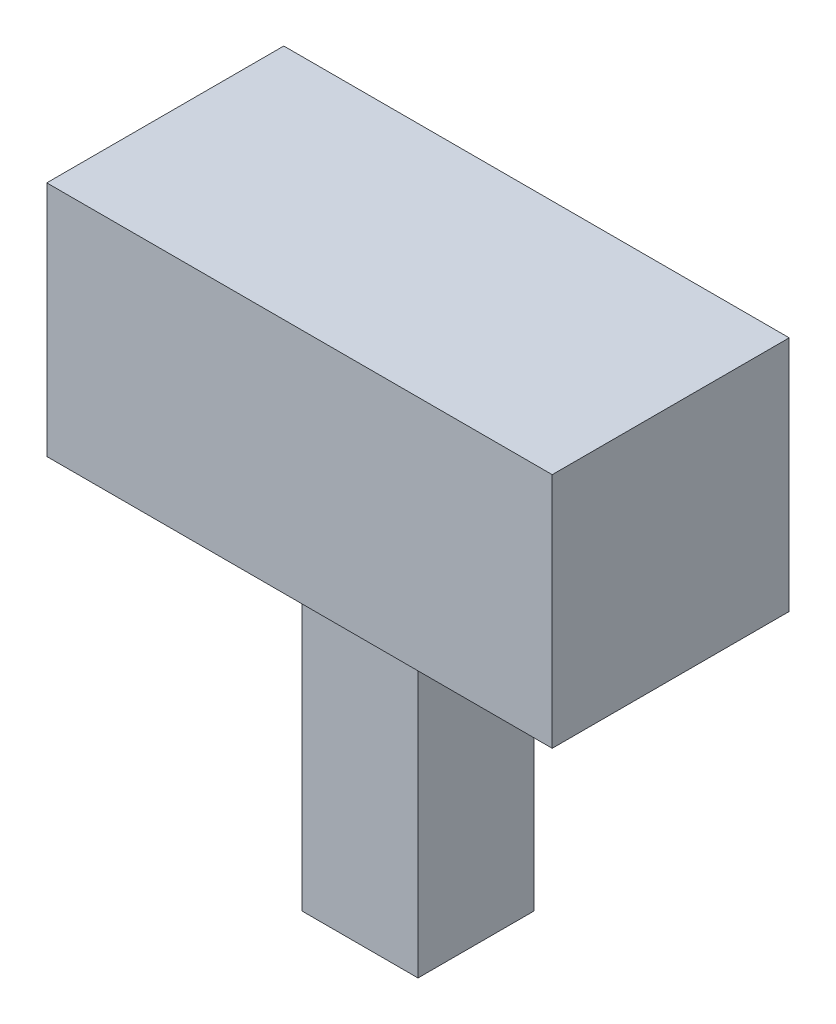
from build123d import *

# Parameters (mm, degrees)
SKETCH_1_W           = 9.8
SKETCH_1_H           = 9.8
EXTRUDE_1_DEPTH      = 9.8
SKETCH_2_W           = 4.8
SKETCH_2_H           = 4.8
EXTRUDE_2_DEPTH      = 13.5
SKETCH_4_W           = 9.8
SKETCH_4_H           = 9.8
EXTRUDE_4_DEPTH      = 5.55
SKETCH_6_W           = 9.8
SKETCH_6_H           = 9.8
EXTRUDE_5_DEPTH      = 5.55
EXTRUDE_5_DEPTH_BACK = 15.35
CUT_EXTRUDE_1_DEPTH  = 1
CUT_EXTRUDE_2_DEPTH  = 1


with BuildPart() as part:
    # 草图1 → 凸台-拉伸1 (new body)
    with BuildSketch(Plane.XY):
        with Locations((0.756375839, 0.263087248)):
            Rectangle(SKETCH_1_W, SKETCH_1_H)
    extrude(amount=EXTRUDE_1_DEPTH)

    # 草图2 → 凸台-拉伸2 (add)
    with BuildSketch(Plane.XZ.offset(4.636912752)):
        with Locations((0.756375839, 4.9)):
            Rectangle(SKETCH_2_W, SKETCH_2_H)
    extrude(amount=EXTRUDE_2_DEPTH)

    # 草图4 → 凸台-拉伸4 (add)
    with BuildSketch(Plane(origin=(5.656375839, 0, 0), x_dir=(0, 0, -1), z_dir=(1, 0, 0))):
        with Locations((-4.9, 0.263087248)):
            Rectangle(SKETCH_4_W, SKETCH_4_H)
    extrude(amount=EXTRUDE_4_DEPTH)

    # 草图6 → 凸台-拉伸5 (add, two sides)
    with BuildSketch(Plane.ZY.offset(4.143624161)) as extrude_5_sk:
        with Locations((4.9, 0.263087248)):
            Rectangle(SKETCH_6_W, SKETCH_6_H)
    extrude(amount=EXTRUDE_5_DEPTH)
    extrude(extrude_5_sk.sketch, amount=-EXTRUDE_5_DEPTH_BACK)

    # 草图7 → 切除-拉伸1 (cut)
    with BuildSketch(Plane(origin=(0, 0, 0), x_dir=(-1, 0, 0), z_dir=(0, 0, -1))):
        with BuildLine():
            Line((-1.929152879, 2.490221957), (-1.858302676, 2.490221957))
            add(Edge.make_bspline(
                [(-1.858302676, 2.490221957), (-1.856417734, 2.458896013), (-1.852718838, 2.397423866), (-1.845317525, 2.304589435), (-1.829200327, 2.209033175), (-1.807695249, 2.107132803), (-1.77108464, 2.001211747), (-1.724850314, 1.91644303), (-1.679762546, 1.85333673), (-1.642647564, 1.810720844), (-1.602372462, 1.773843029), (-1.560474354, 1.741280468), (-1.51488514, 1.716571146), (-1.466783788, 1.699901061), (-1.416690998, 1.690442876), (-1.365401815, 1.691476688), (-1.315799066, 1.696795833), (-1.269966968, 1.708456441), (-1.22823319, 1.722934541), (-1.190186404, 1.743766408), (-1.154241642, 1.773128147), (-1.119141922, 1.812535547), (-1.081677181, 1.861174561), (-1.043853344, 1.920197497), (-1.006982515, 1.988781029), (-0.973062721, 2.066952505), (-0.944757937, 2.154640595), (-0.918704793, 2.250181479), (-0.896861647, 2.353130154), (-0.877239021, 2.461229037), (-0.862549121, 2.574787435), (-0.855230874, 2.652035503), (-0.85148401, 2.69158569)],
                knots=[0, 0, 0, 0, 9.4159e-05, 0.000184772, 0.000279182, 0.000384666, 0.000496941, 0.000614078, 0.000672859, 0.000729406, 0.000783238, 0.000836487, 0.000888211, 0.000937978, 0.000988741, 0.001040201, 0.001091265, 0.001138113, 0.00118176, 0.001223484, 0.001267511, 0.001320288, 0.001381448, 0.001451576, 0.001530323, 0.001614835, 0.001706813, 0.001806498, 0.001911821, 0.00202242, 0.002136018, 0.002255198, 0.002255198, 0.002255198, 0.002255198], degree=3))
            Line((-0.85148401, 2.69158569), (-0.841788719, 2.988410748))
            Line((-0.841788719, 2.988410748), (-0.836568178, 3.18455394))
            add(Edge.make_bspline(
                [(-0.836568178, 3.18455394), (-0.843589049, 3.164594334), (-0.856830328, 3.126950758), (-0.878435789, 3.074712531), (-0.896514508, 3.028640339), (-0.919208562, 2.976418811), (-0.95249876, 2.917257284), (-1.000025726, 2.849205863), (-1.062082262, 2.784552309), (-1.124895683, 2.735836485), (-1.183713692, 2.701911369), (-1.234947576, 2.683882138), (-1.291088339, 2.673645671), (-1.330239127, 2.672196343), (-1.350418593, 2.671449317)],
                knots=[0, 0, 0, 0, 6.3462e-05, 0.000119689, 0.000169546, 0.000211951, 0.000290401, 0.000372763, 0.000460329, 0.000558185, 0.000610267, 0.000663344, 0.000720245, 0.000780769, 0.000780769, 0.000780769, 0.000780769], degree=3))
            add(Edge.make_bspline(
                [(-1.350418593, 2.671449317), (-1.37990256, 2.671576781), (-1.438145604, 2.671828577), (-1.523672622, 2.69638659), (-1.604197405, 2.741470882), (-1.665466257, 2.795633424), (-1.713111519, 2.84864321), (-1.747661794, 2.897085955), (-1.783269574, 2.950877813), (-1.828284568, 3.032010039), (-1.877611045, 3.141010112), (-1.913167134, 3.257202196), (-1.931616142, 3.355481922), (-1.942188762, 3.435380314), (-1.947777119, 3.521569367), (-1.950515393, 3.643716606), (-1.946208286, 3.797677519), (-1.934766563, 3.920200031), (-1.929152879, 3.980313582)],
                knots=[0, 0, 0, 0, 8.8117e-05, 0.000174068, 0.000263529, 0.000362946, 0.000417882, 0.000477101, 0.000541226, 0.000611346, 0.000755222, 0.000899376, 0.000974557, 0.001055037, 0.00114101, 0.001233515, 0.001421527, 0.001602624, 0.001602624, 0.001602624, 0.001602624], degree=3))
            add(Edge.make_bspline(
                [(-1.929152879, 3.980313582), (-1.926131569, 4.009963489), (-1.919851242, 4.071596065), (-1.900759521, 4.166448756), (-1.877093911, 4.267808335), (-1.847933537, 4.371886037), (-1.812526499, 4.471172803), (-1.766446279, 4.555869781), (-1.712445142, 4.623177826), (-1.65007766, 4.670351268), (-1.58741635, 4.701690833), (-1.531860287, 4.728914635), (-1.481799718, 4.746796835), (-1.44994469, 4.752564591), (-1.435438836, 4.75519106)],
                knots=[0, 0, 0, 0, 8.9361e-05, 0.000185753, 0.000289951, 0.000401613, 0.000509938, 0.000605411, 0.000689632, 0.000766752, 0.000837822, 0.000899547, 0.000952378, 0.00099655, 0.00099655, 0.00099655, 0.00099655], degree=3))
            add(Edge.make_bspline(
                [(-1.435438836, 4.75519106), (-1.411514959, 4.755842472), (-1.362470692, 4.757177877), (-1.300426317, 4.744318961), (-1.248457166, 4.727155136), (-1.205998951, 4.706098544), (-1.159540853, 4.680447117), (-1.111760087, 4.646788269), (-1.063440086, 4.607574547), (-1.018910894, 4.559612188), (-0.978790464, 4.504429988), (-0.932051704, 4.421477499), (-0.881373904, 4.3126676), (-0.835068519, 4.199790384), (-0.803663424, 4.101275091), (-0.784518827, 4.013245665), (-0.765407533, 3.912146378), (-0.751700548, 3.801857353), (-0.737750354, 3.693508845), (-0.726882045, 3.596486171), (-0.717513158, 3.516008181), (-0.70953122, 3.428758629), (-0.701863831, 3.32438971), (-0.698445855, 3.198741896), (-0.696171497, 3.076671711), (-0.695788139, 2.998604314), (-0.695613565, 2.963053834)],
                knots=[0, 0, 0, 0, 7.16e-05, 0.000146781, 0.000188525, 0.000235563, 0.000288661, 0.000347621, 0.000410644, 0.000475016, 0.000543336, 0.000614843, 0.000760285, 0.000903207, 0.000980576, 0.001070127, 0.001173254, 0.001289169, 0.001403411, 0.001501007, 0.001582048, 0.001646463, 0.00176384, 0.001895921, 0.002023471, 0.002130121, 0.002130121, 0.002130121, 0.002130121], degree=3))
            add(Edge.make_bspline(
                [(-0.695613565, 2.963053834), (-0.699032924, 2.903618052), (-0.705562648, 2.79011748), (-0.719823543, 2.627228103), (-0.737154266, 2.47676244), (-0.757468792, 2.335238712), (-0.784516787, 2.198865007), (-0.81988558, 2.064644209), (-0.869966964, 1.929752271), (-0.923992909, 1.819521874), (-0.972452167, 1.734753552), (-1.012871006, 1.681508739), (-1.05214928, 1.636649435), (-1.105804763, 1.594596213), (-1.170835391, 1.558419889), (-1.246278201, 1.531583892), (-1.317591524, 1.521866966), (-1.363085959, 1.523079452), (-1.385470799, 1.523676037)],
                knots=[0, 0, 0, 0, 0.000178595, 0.000341051, 0.000490451, 0.000632944, 0.000769845, 0.000907338, 0.001048921, 0.001200685, 0.001275253, 0.001341331, 0.00140098, 0.001453509, 0.001544999, 0.001623065, 0.00169236, 0.001759481, 0.001759481, 0.001759481, 0.001759481], degree=3))
            add(Edge.make_bspline(
                [(-1.385470799, 1.523676037), (-1.40540655, 1.524978018), (-1.444573141, 1.527535944), (-1.502222665, 1.538931195), (-1.557203911, 1.557223265), (-1.610463832, 1.579868878), (-1.660328513, 1.609765734), (-1.704872911, 1.647870649), (-1.746797214, 1.691012901), (-1.782252727, 1.742744337), (-1.814245338, 1.800258171), (-1.842709178, 1.864146134), (-1.866985397, 1.934336023), (-1.888114559, 2.010727314), (-1.904185835, 2.094066294), (-1.916681896, 2.18443647), (-1.925849485, 2.281978532), (-1.928028805, 2.349495112), (-1.929152879, 2.384319549)],
                knots=[0, 0, 0, 0, 5.9891e-05, 0.000117665, 0.000175683, 0.000233462, 0.000291018, 0.000349267, 0.000408879, 0.000470954, 0.000536728, 0.000606167, 0.000680466, 0.00075935, 0.000843744, 0.000934871, 0.001032978, 0.001137485, 0.001137485, 0.001137485, 0.001137485], degree=3))
            Line((-1.929152879, 2.384319549), (-1.929152879, 2.490221957))
        make_face()
        with BuildLine():
            add(Edge.make_bspline(
                [(-0.90741838, 3.708099647), (-0.908443626, 3.753420486), (-0.910503528, 3.844478122), (-0.931328142, 3.981202173), (-0.963007431, 4.119280766), (-1.005242261, 4.231958595), (-1.044403093, 4.320201109), (-1.080402134, 4.380413995), (-1.120387243, 4.435061094), (-1.164433471, 4.483415987), (-1.213439596, 4.523800134), (-1.268183655, 4.552208796), (-1.328196078, 4.567550357), (-1.369475567, 4.568338228), (-1.39069134, 4.568743158)],
                knots=[0, 0, 0, 0, 0.000135865, 0.000272977, 0.000414072, 0.000560112, 0.000633192, 0.000703411, 0.000770088, 0.00083606, 0.000899188, 0.00095956, 0.001019614, 0.001083116, 0.001083116, 0.001083116, 0.001083116], degree=3))
            add(Edge.make_bspline(
                [(-1.39069134, 4.568743158), (-1.40973754, 4.56704024), (-1.448191168, 4.563602106), (-1.503925289, 4.5437766), (-1.557873339, 4.514150557), (-1.60801798, 4.474109943), (-1.653683504, 4.427664069), (-1.693293024, 4.376731164), (-1.723626976, 4.321067627), (-1.747379547, 4.26167944), (-1.763505911, 4.197412206), (-1.778723662, 4.128567273), (-1.791192855, 4.053869614), (-1.804713068, 3.948766687), (-1.815007498, 3.818377964), (-1.823974897, 3.690318745), (-1.823502999, 3.589627035), (-1.81657247, 3.51157414), (-1.803040392, 3.429631104), (-1.78978929, 3.374159447), (-1.782977724, 3.345644927)],
                knots=[0, 0, 0, 0, 5.7169e-05, 0.000115422, 0.000175835, 0.000241181, 0.000307102, 0.000370944, 0.000434038, 0.000496635, 0.000562307, 0.000632523, 0.000708172, 0.000789391, 0.000950361, 0.00110049, 0.001174327, 0.001252179, 0.001335307, 0.001423238, 0.001423238, 0.001423238, 0.001423238], degree=3))
            add(Edge.make_bspline(
                [(-1.782977724, 3.345644927), (-1.777743837, 3.321644378), (-1.767312442, 3.273810104), (-1.743135118, 3.204814192), (-1.717122035, 3.13710766), (-1.684522314, 3.07424642), (-1.649265947, 3.017291172), (-1.612588387, 2.968246365), (-1.57320985, 2.929838985), (-1.533447704, 2.899630175), (-1.491132423, 2.879309273), (-1.447496657, 2.865536314), (-1.401514592, 2.859313678), (-1.370558803, 2.861344335), (-1.354893343, 2.862371967)],
                knots=[0, 0, 0, 0, 7.3622e-05, 0.000146733, 0.000219024, 0.000291069, 0.00035874, 0.000419899, 0.000474219, 0.000523294, 0.000568989, 0.00061428, 0.000660163, 0.000707171, 0.000707171, 0.000707171, 0.000707171], degree=3))
            add(Edge.make_bspline(
                [(-1.354893343, 2.862371967), (-1.336134442, 2.863930007), (-1.299226537, 2.866995432), (-1.246512264, 2.883224129), (-1.197801599, 2.907661145), (-1.153294018, 2.939734626), (-1.113965389, 2.97797309), (-1.077674255, 3.017728215), (-1.047830756, 3.060971236), (-1.021684419, 3.106812349), (-0.999375123, 3.15774952), (-0.978710621, 3.21435792), (-0.959169201, 3.27755413), (-0.941493048, 3.347725321), (-0.925001607, 3.425623795), (-0.91564448, 3.512280145), (-0.908447058, 3.607296475), (-0.907771181, 3.67352766), (-0.90741838, 3.708099647)],
                knots=[0, 0, 0, 0, 5.6336e-05, 0.00011084, 0.000164204, 0.000219257, 0.000274651, 0.000328534, 0.000380468, 0.0004319, 0.000486649, 0.000547053, 0.000612632, 0.000684985, 0.000764113, 0.000851253, 0.000946206, 0.001049895, 0.001049895, 0.001049895, 0.001049895], degree=3))
        make_face(mode=Mode.SUBTRACT)
        with BuildLine():
            add(Edge.make_bspline(
                [(0.201573736, 3.400833506), (0.188177537, 3.409571213), (0.161270786, 3.427121215), (0.119825519, 3.453139603), (0.080803725, 3.486699292), (0.044686531, 3.530322654), (0.014279151, 3.587635575), (-0.016635008, 3.654005118), (-0.042122529, 3.728434388), (-0.064817032, 3.808216121), (-0.078227437, 3.898306869), (-0.081371141, 3.998700863), (-0.078596021, 4.101782967), (-0.072682408, 4.16976381), (-0.069894409, 4.201813689)],
                knots=[0, 0, 0, 0, 4.7992e-05, 9.6394e-05, 0.000146628, 0.000201726, 0.000265184, 0.000340609, 0.000421279, 0.000500883, 0.000589167, 0.000693674, 0.000801855, 0.00089835, 0.00089835, 0.00089835, 0.00089835], degree=3))
            add(Edge.make_bspline(
                [(-0.069894409, 4.201813689), (-0.066300062, 4.224512814), (-0.05929012, 4.268782205), (-0.042753266, 4.331824804), (-0.022714715, 4.390133415), (0.010263385, 4.46054304), (0.061803971, 4.541636537), (0.123514299, 4.614437129), (0.179066515, 4.663617858), (0.219876875, 4.695246978), (0.261894675, 4.717717068), (0.316479376, 4.737021634), (0.382105001, 4.750822723), (0.434201842, 4.753787239), (0.458871839, 4.75519106)],
                knots=[0, 0, 0, 0, 6.8908e-05, 0.000134389, 0.000195243, 0.000253635, 0.000367235, 0.000482507, 0.000538497, 0.000589658, 0.000637038, 0.000680684, 0.000763036, 0.00083711, 0.00083711, 0.00083711, 0.00083711], degree=3))
            add(Edge.make_bspline(
                [(0.458871839, 4.75519106), (0.478076137, 4.753669783), (0.516357737, 4.750637289), (0.572830016, 4.73769147), (0.627557587, 4.717283641), (0.680335842, 4.690149068), (0.731311259, 4.658113743), (0.776603425, 4.617787716), (0.818519334, 4.572780398), (0.865847937, 4.504405389), (0.915231957, 4.412735491), (0.948577888, 4.313669453), (0.966525867, 4.229351836), (0.976158861, 4.158321279), (0.980832041, 4.07931786), (0.981873722, 4.024071499), (0.982417545, 3.995229415)],
                knots=[0, 0, 0, 0, 5.7735e-05, 0.000115088, 0.000173136, 0.000232505, 0.000292909, 0.000353175, 0.000413878, 0.000476994, 0.000602111, 0.000724986, 0.000789055, 0.000860565, 0.000939791, 0.001026332, 0.001026332, 0.001026332, 0.001026332], degree=3))
            add(Edge.make_bspline(
                [(0.982417545, 3.995229415), (0.980411894, 3.963892769), (0.976423091, 3.90157101), (0.967959317, 3.823491166), (0.955192368, 3.759707144), (0.93920841, 3.708028083), (0.916590195, 3.652360347), (0.889203898, 3.595246178), (0.860596022, 3.5413953), (0.831132406, 3.497505031), (0.805403613, 3.462677411), (0.784880701, 3.447706228), (0.775833271, 3.441106252)],
                knots=[0, 0, 0, 0, 9.4209e-05, 0.000187361, 0.000235336, 0.000289126, 0.00034937, 0.000415422, 0.000479168, 0.000531914, 0.000574313, 0.000607741, 0.000607741, 0.000607741, 0.000607741], degree=3))
            Line((0.775833271, 3.441106252), (0.715424151, 3.400833506))
            add(Edge.make_bspline(
                [(0.715424151, 3.400833506), (0.731080086, 3.387156505), (0.760525761, 3.361432809), (0.802103226, 3.325247242), (0.836267504, 3.291467196), (0.874627406, 3.251568409), (0.916671853, 3.199670062), (0.961723885, 3.130253753), (1.003155673, 3.049938953), (1.040344867, 2.957242146), (1.072075319, 2.849801216), (1.094574867, 2.728814014), (1.110032869, 2.598738033), (1.116702708, 2.463228517), (1.114334913, 2.322016612), (1.10012794, 2.226855003), (1.092794703, 2.177735274)],
                knots=[0, 0, 0, 0, 6.2371e-05, 0.000117307, 0.000165299, 0.000206446, 0.00028332, 0.000365235, 0.000454297, 0.000554011, 0.000664448, 0.000789797, 0.000922728, 0.001057138, 0.001196651, 0.00134549, 0.00134549, 0.00134549, 0.00134549], degree=3))
            add(Edge.make_bspline(
                [(1.092794703, 2.177735274), (1.079974052, 2.122903906), (1.05504409, 2.016283421), (1.00576971, 1.891112423), (0.960412247, 1.802187417), (0.926514282, 1.745080798), (0.890878129, 1.697375492), (0.840995867, 1.647954416), (0.773031347, 1.599366845), (0.683983804, 1.558361531), (0.589690763, 1.534003749), (0.525628852, 1.533580699), (0.493924045, 1.533371328)],
                knots=[0, 0, 0, 0, 0.00016877, 0.000328176, 0.000401888, 0.000468142, 0.000527211, 0.000579946, 0.000678261, 0.00077603, 0.000872802, 0.000967624, 0.000967624, 0.000967624, 0.000967624], degree=3))
            add(Edge.make_bspline(
                [(0.493924045, 1.533371328), (0.468989304, 1.534395471), (0.419906399, 1.536411449), (0.34773234, 1.551890228), (0.278840423, 1.57754167), (0.21301341, 1.612566873), (0.152205434, 1.657192517), (0.094912392, 1.707655033), (0.044047891, 1.766672836), (-0.001643915, 1.832699303), (-0.041720835, 1.906091955), (-0.076827125, 1.986217002), (-0.106384692, 2.07317789), (-0.131535931, 2.165838006), (-0.151469359, 2.262728592), (-0.165688938, 2.362345905), (-0.173872851, 2.463483683), (-0.175154535, 2.531474933), (-0.175796816, 2.565546909)],
                knots=[0, 0, 0, 0, 7.4762e-05, 0.000147165, 0.000220313, 0.000294717, 0.000370057, 0.000446113, 0.000523287, 0.000603142, 0.000686591, 0.00077375, 0.000865261, 0.000961872, 0.001061624, 0.001161821, 0.00126358, 0.001365797, 0.001365797, 0.001365797, 0.001365797], degree=3))
            add(Edge.make_bspline(
                [(-0.175796816, 2.565546909), (-0.175499034, 2.596146434), (-0.174924282, 2.655206935), (-0.166872819, 2.740044367), (-0.156523776, 2.81798383), (-0.139886657, 2.888721854), (-0.118965991, 2.952638176), (-0.098949176, 3.011897928), (-0.075303884, 3.06479413), (-0.044673022, 3.127001807), (-0.003342789, 3.193047582), (0.049519012, 3.257558787), (0.098441301, 3.307323791), (0.127991631, 3.337440156), (0.141164616, 3.350865468)],
                knots=[0, 0, 0, 0, 9.176e-05, 0.000177106, 0.000255471, 0.00032747, 0.000394695, 0.000457204, 0.000514982, 0.000568346, 0.000665187, 0.000747886, 0.000818042, 0.000874472, 0.000874472, 0.000874472, 0.000874472], degree=3))
            Line((0.141164616, 3.350865468), (0.201573736, 3.400833506))
        make_face()
        with BuildLine():
            add(Edge.make_bspline(
                [(0.977197004, 2.51035833), (0.975791397, 2.543440417), (0.97309093, 2.606998092), (0.963833148, 2.698562036), (0.948141266, 2.782014044), (0.927843413, 2.857871707), (0.904331009, 2.926539911), (0.880296833, 2.989400421), (0.853151814, 3.045509095), (0.82478781, 3.096019204), (0.79425271, 3.141279327), (0.7600745, 3.18135699), (0.723182973, 3.216974245), (0.682940903, 3.247940862), (0.639908092, 3.27497593), (0.591104963, 3.293105848), (0.538823943, 3.306305155), (0.502210589, 3.30914179), (0.483482962, 3.310592722)],
                knots=[0, 0, 0, 0, 9.9328e-05, 0.000190829, 0.000275813, 0.000353784, 0.000426187, 0.000493494, 0.000555539, 0.000612984, 0.000667181, 0.000719034, 0.000770725, 0.000820699, 0.00087122, 0.000922463, 0.000976186, 0.001032438, 0.001032438, 0.001032438, 0.001032438], degree=3))
            add(Edge.make_bspline(
                [(0.483482962, 3.310592722), (0.460520291, 3.309616779), (0.415041661, 3.307683881), (0.348532395, 3.291316587), (0.28518427, 3.264861483), (0.225250047, 3.228268304), (0.170303842, 3.18069102), (0.121609666, 3.122359801), (0.078674036, 3.053740478), (0.043789082, 2.974599134), (0.014553293, 2.887254241), (-0.006414271, 2.792441964), (-0.021596179, 2.69128736), (-0.028468222, 2.585561316), (-0.028994147, 2.479356724), (-0.020516937, 2.376925015), (-0.005722349, 2.279826305), (0.011760526, 2.218361672), (0.020346376, 2.188176357)],
                knots=[0, 0, 0, 0, 6.8811e-05, 0.000136284, 0.000204151, 0.000274116, 0.00034603, 0.000421181, 0.000501263, 0.000588044, 0.000680022, 0.000777175, 0.000878956, 0.000986609, 0.001094748, 0.001197251, 0.001294724, 0.001388789, 0.001388789, 0.001388789, 0.001388789], degree=3))
            add(Edge.make_bspline(
                [(0.020346376, 2.188176357), (0.032310727, 2.151006734), (0.056724779, 2.075159659), (0.102263168, 1.986263603), (0.14336483, 1.919605287), (0.174067962, 1.87533692), (0.203652097, 1.837222428), (0.241304683, 1.795695423), (0.294074276, 1.756766045), (0.364023967, 1.72930396), (0.434913476, 1.718777787), (0.481229122, 1.719479839), (0.503619335, 1.719819229)],
                knots=[0, 0, 0, 0, 0.000116992, 0.00023873, 0.000298337, 0.00035192, 0.000400259, 0.000443003, 0.000519824, 0.00059447, 0.000666198, 0.000733323, 0.000733323, 0.000733323, 0.000733323], degree=3))
            add(Edge.make_bspline(
                [(0.503619335, 1.719819229), (0.521064979, 1.720339638), (0.55598109, 1.721381195), (0.607343557, 1.731443934), (0.657220801, 1.747564629), (0.706561352, 1.768715683), (0.753747623, 1.800368767), (0.795527644, 1.844875934), (0.833326194, 1.900562332), (0.875621278, 1.988902473), (0.918748697, 2.103223922), (0.953770782, 2.240708865), (0.974097653, 2.375483016), (0.976161433, 2.465293113), (0.977197004, 2.51035833)],
                knots=[0, 0, 0, 0, 5.2291e-05, 0.000104656, 0.000156309, 0.000209392, 0.000265241, 0.000325369, 0.000391358, 0.000466402, 0.000618633, 0.00075719, 0.000891349, 0.001026469, 0.001026469, 0.001026469, 0.001026469], degree=3))
        make_face(mode=Mode.SUBTRACT)
        with BuildLine():
            add(Edge.make_bspline(
                [(0.065839664, 3.960177209), (0.068963781, 3.929021324), (0.074959789, 3.869224937), (0.093167757, 3.784648399), (0.120145753, 3.710057269), (0.153427958, 3.646216337), (0.19001962, 3.593886935), (0.224537801, 3.551968477), (0.256676936, 3.521040694), (0.288618202, 3.49997959), (0.324142111, 3.489935967), (0.364160699, 3.483542063), (0.411329805, 3.479556873), (0.445194738, 3.480743147), (0.463346589, 3.481378999)],
                knots=[0, 0, 0, 0, 9.3893e-05, 0.000180205, 0.000258768, 0.000331156, 0.000395494, 0.000450018, 0.000493817, 0.000528996, 0.000563432, 0.000603525, 0.000650657, 0.000705105, 0.000705105, 0.000705105, 0.000705105], degree=3))
            add(Edge.make_bspline(
                [(0.463346589, 3.481378999), (0.480000103, 3.481794532), (0.511097901, 3.482570475), (0.554812875, 3.484860151), (0.591830798, 3.491179285), (0.624291546, 3.498139729), (0.652803117, 3.5106329), (0.679519242, 3.528277239), (0.704693601, 3.551837231), (0.729471499, 3.580354099), (0.753170636, 3.61495987), (0.772314464, 3.657271524), (0.791573779, 3.70499017), (0.811920435, 3.779382177), (0.832242585, 3.88066693), (0.842770899, 4.008075011), (0.841257314, 4.13771162), (0.820898005, 4.22117584), (0.810885476, 4.262222809)],
                knots=[0, 0, 0, 0, 4.999e-05, 9.3349e-05, 0.000131113, 0.000162587, 0.00019265, 0.000223885, 0.000258199, 0.000295734, 0.000337104, 0.000383469, 0.000434712, 0.000491363, 0.000614515, 0.000744021, 0.000874612, 0.001000983, 0.001000983, 0.001000983, 0.001000983], degree=3))
            add(Edge.make_bspline(
                [(0.810885476, 4.262222809), (0.801344623, 4.28724361), (0.781938612, 4.3381357), (0.751286961, 4.399534957), (0.719772314, 4.446043615), (0.68978971, 4.477551312), (0.653244351, 4.504601697), (0.598813744, 4.533912855), (0.527540415, 4.56235692), (0.467605902, 4.566666996), (0.438735466, 4.568743158)],
                knots=[0, 0, 0, 0, 8.0324e-05, 0.000163379, 0.00020517, 0.000248426, 0.000293173, 0.00034091, 0.000433874, 0.000520273, 0.000520273, 0.000520273, 0.000520273], degree=3))
            add(Edge.make_bspline(
                [(0.438735466, 4.568743158), (0.419742339, 4.567667113), (0.383547505, 4.565616514), (0.333193791, 4.552297758), (0.288503592, 4.534290015), (0.240130217, 4.498244939), (0.190178023, 4.443464091), (0.137700546, 4.369542355), (0.097667234, 4.280840241), (0.070580619, 4.180056675), (0.056785624, 4.070761792), (0.062827124, 3.996971876), (0.065839664, 3.960177209)],
                knots=[0, 0, 0, 0, 5.692e-05, 0.000108471, 0.000155575, 0.000200483, 0.00028805, 0.000377009, 0.000471445, 0.000578195, 0.000689297, 0.000799798, 0.000799798, 0.000799798, 0.000799798], degree=3))
        make_face(mode=Mode.SUBTRACT)
    extrude(amount=-CUT_EXTRUDE_1_DEPTH, mode=Mode.SUBTRACT)

    # 草图8 → 切除-拉伸2 (cut)
    with BuildSketch(Plane(origin=(0, 0, 0), x_dir=(-1, 0, 0), z_dir=(0, 0, -1))):
        with BuildLine():
            Line((-1.209381992, -1.558817929), (-1.919375599, -1.599090676))
            Line((-1.919375599, -1.599090676), (-1.969343637, -1.674415628))
            add(Edge.make_bspline(
                [(-1.969343637, -1.674415628), (-1.972604334, -1.682309126), (-1.977532259, -1.69423865), (-1.995752047, -1.70654145), (-2.009420509, -1.688894131), (-2.015879433, -1.677385425), (-2.020057466, -1.669940878)],
                knots=[0, 0, 0, 0, 2.6092e-05, 3.9433e-05, 5.4237e-05, 8.1353e-05, 8.1353e-05, 8.1353e-05, 8.1353e-05], degree=3))
            Line((-2.020057466, -1.669940878), (-2.115518791, -1.478272436))
            add(Edge.make_bspline(
                [(-2.115518791, -1.478272436), (-2.119602581, -1.466954084), (-2.126336707, -1.448290239), (-2.131239401, -1.42323882), (-2.129845436, -1.405570474), (-2.126609984, -1.396443946), (-2.125214082, -1.392506401)],
                knots=[0, 0, 0, 0, 3.6084e-05, 5.9503e-05, 7.5978e-05, 8.8479e-05, 8.8479e-05, 8.8479e-05, 8.8479e-05], degree=3))
            Line((-2.125214082, -1.392506401), (-2.084941336, -1.38281111))
            Line((-2.084941336, -1.38281111), (-2.029752757, -1.352233654))
            Line((-2.029752757, -1.352233654), (-1.178804536, 0.701676424))
            Line((-1.178804536, 0.701676424), (-1.068427379, 0.701676424))
            Line((-1.068427379, 0.701676424), (-1.068427379, -1.372370028))
            add(Edge.make_bspline(
                [(-1.068427379, -1.372370028), (-1.058055833, -1.37244866), (-1.04042026, -1.372582365), (-1.024337839, -1.365565116), (-1.01771355, -1.362674737)],
                knots=[0, 0, 0, 0, 3.0659e-05, 5.2132e-05, 5.2132e-05, 5.2132e-05, 5.2132e-05], degree=3))
            Line((-1.01771355, -1.362674737), (-0.942388597, -1.332097281))
            add(Edge.make_bspline(
                [(-0.942388597, -1.332097281), (-0.932650953, -1.32846294), (-0.91529391, -1.321984843), (-0.892944472, -1.312255925), (-0.877123211, -1.3047651), (-0.869751257, -1.299107632), (-0.867063645, -1.297045076)],
                knots=[0, 0, 0, 0, 3.1163e-05, 5.5547e-05, 7.3227e-05, 8.3371e-05, 8.3371e-05, 8.3371e-05, 8.3371e-05], degree=3))
            Line((-0.867063645, -1.297045076), (-0.83201144, -1.267213412))
            Line((-0.83201144, -1.267213412), (-0.691056827, -1.412642774))
            add(Edge.make_bspline(
                [(-0.691056827, -1.412642774), (-0.68387608, -1.421284299), (-0.67212149, -1.435430124), (-0.666991108, -1.459369098), (-0.671883681, -1.47555831), (-0.681029714, -1.487216839), (-0.696972186, -1.492103791), (-0.708707066, -1.492784491), (-0.71566795, -1.493188268)],
                knots=[0, 0, 0, 0, 3.3303e-05, 5.4515e-05, 7.0088e-05, 8.2788e-05, 9.7192e-05, 0.000118194, 0.000118194, 0.000118194, 0.000118194], degree=3))
            Line((-0.71566795, -1.493188268), (-1.068427379, -1.533461014))
            Line((-1.068427379, -1.533461014), (-1.068427379, -2.435123064))
            add(Edge.make_bspline(
                [(-1.068427379, -2.435123064), (-1.068445332, -2.437857985), (-1.06850575, -2.447062043), (-1.067347314, -2.46643776), (-1.066877574, -2.497267817), (-1.0662731, -2.535578038), (-1.065237876, -2.574019446), (-1.065572344, -2.605154956), (-1.067590505, -2.624789323), (-1.072337181, -2.637407662), (-1.08162865, -2.639667063), (-1.086397785, -2.637480056), (-1.088563752, -2.636486797)],
                knots=[0, 0, 0, 0, 8.204e-06, 2.7609e-05, 5.8195e-05, 0.000100712, 0.000142483, 0.000173815, 0.000193434, 0.000202778, 0.000211282, 0.000218357, 0.000218357, 0.000218357, 0.000218357], degree=3))
            add(Edge.make_bspline(
                [(-1.088563752, -2.636486797), (-1.092774608, -2.63398392), (-1.105468385, -2.626438905), (-1.116593545, -2.602090322), (-1.129961149, -2.576817931), (-1.135970521, -2.558519696), (-1.138531789, -2.550720763)],
                knots=[0, 0, 0, 0, 1.4481e-05, 4.3652e-05, 7.6678e-05, 0.00010121, 0.00010121, 0.00010121, 0.00010121], degree=3))
            Line((-1.138531789, -2.550720763), (-1.184025077, -2.459734187))
            Line((-1.184025077, -2.459734187), (-1.209381992, -2.389629776))
            add(Edge.make_bspline(
                [(-1.209381992, -2.389629776), (-1.21323806, -2.381228797), (-1.220215691, -2.366027058), (-1.227859256, -2.345072484), (-1.234683781, -2.329602413), (-1.238482815, -2.311197745), (-1.234026434, -2.282446378), (-1.224204828, -2.242182725), (-1.212409598, -2.199139833), (-1.206867756, -2.159808251), (-1.204592664, -2.125901242), (-1.204307247, -2.103994891), (-1.204161451, -2.092804718)],
                knots=[0, 0, 0, 0, 2.7715e-05, 5.0151e-05, 6.691e-05, 7.8319e-05, 0.000106004, 0.00015268, 0.000203328, 0.000239504, 0.000271651, 0.00030522, 0.00030522, 0.00030522, 0.00030522], degree=3))
            Line((-1.204161451, -2.092804718), (-1.209381992, -1.558817929))
        make_face()
        Polygon((-1.204161451, -1.392506401), (-1.204161451, 0.278812585), (-1.914155058, -1.428304398), align=None, mode=Mode.SUBTRACT)
        with BuildLine():
            add(Edge.make_bspline(
                [(0.136026063, -0.663122212), (0.122629864, -0.654384505), (0.095723113, -0.636834502), (0.054277846, -0.610816114), (0.015256052, -0.577256425), (-0.020861142, -0.533633063), (-0.051268522, -0.476320143), (-0.082182681, -0.409950599), (-0.107670202, -0.33552133), (-0.130364705, -0.255739597), (-0.14377511, -0.165648848), (-0.146918814, -0.065254855), (-0.144143694, 0.037827249), (-0.138230081, 0.105808093), (-0.135442081, 0.137857971)],
                knots=[0, 0, 0, 0, 4.7992e-05, 9.6394e-05, 0.000146628, 0.000201726, 0.000265184, 0.000340609, 0.000421279, 0.000500883, 0.000589167, 0.000693674, 0.000801855, 0.00089835, 0.00089835, 0.00089835, 0.00089835], degree=3))
            add(Edge.make_bspline(
                [(-0.135442081, 0.137857971), (-0.131847735, 0.160557096), (-0.124837793, 0.204826487), (-0.108300939, 0.267869087), (-0.088262388, 0.326177697), (-0.055284288, 0.396587322), (-0.003743702, 0.47768082), (0.057966626, 0.550481411), (0.113518842, 0.599662141), (0.154329202, 0.63129126), (0.196347002, 0.65376135), (0.250931703, 0.673065916), (0.316557328, 0.686867006), (0.368654169, 0.689831522), (0.393324166, 0.691235342)],
                knots=[0, 0, 0, 0, 6.8908e-05, 0.000134389, 0.000195243, 0.000253635, 0.000367235, 0.000482507, 0.000538497, 0.000589658, 0.000637038, 0.000680684, 0.000763036, 0.00083711, 0.00083711, 0.00083711, 0.00083711], degree=3))
            add(Edge.make_bspline(
                [(0.393324166, 0.691235342), (0.412528464, 0.689714065), (0.450810064, 0.686681571), (0.507282344, 0.673735753), (0.562009914, 0.653327924), (0.614788169, 0.62619335), (0.665763586, 0.594158026), (0.711055752, 0.553831998), (0.752971661, 0.50882468), (0.800300264, 0.440449671), (0.849684284, 0.348779774), (0.883030216, 0.249713736), (0.900978194, 0.165396118), (0.910611189, 0.094365562), (0.915284369, 0.015362142), (0.916326049, -0.039884218), (0.916869873, -0.068726303)],
                knots=[0, 0, 0, 0, 5.7735e-05, 0.000115088, 0.000173136, 0.000232505, 0.000292909, 0.000353175, 0.000413878, 0.000476994, 0.000602111, 0.000724986, 0.000789055, 0.000860565, 0.000939791, 0.001026332, 0.001026332, 0.001026332, 0.001026332], degree=3))
            add(Edge.make_bspline(
                [(0.916869873, -0.068726303), (0.914864222, -0.100062948), (0.910875419, -0.162384708), (0.902411644, -0.240464551), (0.889644695, -0.304248573), (0.873660737, -0.355927635), (0.851042523, -0.411595371), (0.823656225, -0.468709539), (0.795048349, -0.522560417), (0.765584733, -0.566450686), (0.73985594, -0.601278307), (0.719333028, -0.616249489), (0.710285598, -0.622849465)],
                knots=[0, 0, 0, 0, 9.4209e-05, 0.000187361, 0.000235336, 0.000289126, 0.00034937, 0.000415422, 0.000479168, 0.000531914, 0.000574313, 0.000607741, 0.000607741, 0.000607741, 0.000607741], degree=3))
            Line((0.710285598, -0.622849465), (0.649876478, -0.663122212))
            add(Edge.make_bspline(
                [(0.649876478, -0.663122212), (0.665532413, -0.676799212), (0.694978088, -0.702522909), (0.736555553, -0.738708476), (0.770719831, -0.772488521), (0.809079733, -0.812387309), (0.85112418, -0.864285655), (0.896176212, -0.933701965), (0.937608, -1.014016765), (0.974797194, -1.106713572), (1.006527646, -1.214154501), (1.029027194, -1.335141704), (1.044485196, -1.465217685), (1.051155035, -1.6007272), (1.04878724, -1.741939105), (1.034580267, -1.837100715), (1.02724703, -1.886220443)],
                knots=[0, 0, 0, 0, 6.2371e-05, 0.000117307, 0.000165299, 0.000206446, 0.00028332, 0.000365235, 0.000454297, 0.000554011, 0.000664448, 0.000789797, 0.000922728, 0.001057138, 0.001196651, 0.00134549, 0.00134549, 0.00134549, 0.00134549], degree=3))
            add(Edge.make_bspline(
                [(1.02724703, -1.886220443), (1.01442638, -1.941051811), (0.989496417, -2.047672296), (0.940222037, -2.172843295), (0.894864575, -2.261768301), (0.86096661, -2.31887492), (0.825330456, -2.366580225), (0.775448194, -2.416001302), (0.707483675, -2.464588873), (0.618436131, -2.505594187), (0.52414309, -2.529951969), (0.460081179, -2.530375019), (0.428376372, -2.53058439)],
                knots=[0, 0, 0, 0, 0.00016877, 0.000328176, 0.000401888, 0.000468142, 0.000527211, 0.000579946, 0.000678261, 0.00077603, 0.000872802, 0.000967624, 0.000967624, 0.000967624, 0.000967624], degree=3))
            add(Edge.make_bspline(
                [(0.428376372, -2.53058439), (0.403441631, -2.529560247), (0.354358726, -2.527544268), (0.282184667, -2.512065489), (0.21329275, -2.486414048), (0.147465737, -2.451388844), (0.086657761, -2.406763201), (0.029364719, -2.356300685), (-0.021499782, -2.297282882), (-0.067191588, -2.231256415), (-0.107268508, -2.157863763), (-0.142374798, -2.077738716), (-0.171932365, -1.990777827), (-0.197083604, -1.898117712), (-0.217017031, -1.801227126), (-0.231236611, -1.701609813), (-0.239420524, -1.600472034), (-0.240702208, -1.532480784), (-0.241344489, -1.498408809)],
                knots=[0, 0, 0, 0, 7.4762e-05, 0.000147165, 0.000220313, 0.000294717, 0.000370057, 0.000446113, 0.000523287, 0.000603142, 0.000686591, 0.00077375, 0.000865261, 0.000961872, 0.001061624, 0.001161821, 0.00126358, 0.001365797, 0.001365797, 0.001365797, 0.001365797], degree=3))
            add(Edge.make_bspline(
                [(-0.241344489, -1.498408809), (-0.241046707, -1.467809283), (-0.240471955, -1.408748782), (-0.232420492, -1.32391135), (-0.222071449, -1.245971887), (-0.20543433, -1.175233864), (-0.184513664, -1.111317542), (-0.164496849, -1.05205779), (-0.140851557, -0.999161587), (-0.110220695, -0.93695391), (-0.068890462, -0.870908136), (-0.016028661, -0.806396931), (0.032893629, -0.756631927), (0.062443959, -0.726515561), (0.075616943, -0.713090249)],
                knots=[0, 0, 0, 0, 9.176e-05, 0.000177106, 0.000255471, 0.00032747, 0.000394695, 0.000457204, 0.000514982, 0.000568346, 0.000665187, 0.000747886, 0.000818042, 0.000874472, 0.000874472, 0.000874472, 0.000874472], degree=3))
            Line((0.075616943, -0.713090249), (0.136026063, -0.663122212))
        make_face()
        with BuildLine():
            add(Edge.make_bspline(
                [(0.911649331, -1.553597388), (0.910243725, -1.520515301), (0.907543257, -1.456957626), (0.898285475, -1.365393682), (0.882593593, -1.281941673), (0.86229574, -1.20608401), (0.838783336, -1.137415806), (0.81474916, -1.074555297), (0.787604141, -1.018446622), (0.759240137, -0.967936514), (0.728705037, -0.922676391), (0.694526827, -0.882598728), (0.6576353, -0.846981473), (0.61739323, -0.816014856), (0.574360419, -0.788979788), (0.52555729, -0.77084987), (0.47327627, -0.757650563), (0.436662916, -0.754813927), (0.417935289, -0.753362996)],
                knots=[0, 0, 0, 0, 9.9328e-05, 0.000190829, 0.000275813, 0.000353784, 0.000426187, 0.000493494, 0.000555539, 0.000612984, 0.000667181, 0.000719034, 0.000770725, 0.000820699, 0.00087122, 0.000922463, 0.000976186, 0.001032438, 0.001032438, 0.001032438, 0.001032438], degree=3))
            add(Edge.make_bspline(
                [(0.417935289, -0.753362996), (0.394972618, -0.754338938), (0.349493988, -0.756271837), (0.282984722, -0.772639131), (0.219636597, -0.799094235), (0.159702374, -0.835687414), (0.104756169, -0.883264698), (0.056061993, -0.941595917), (0.013126363, -1.010215239), (-0.02175859, -1.089356584), (-0.05099438, -1.176701476), (-0.071961944, -1.271513754), (-0.087143852, -1.372668358), (-0.094015895, -1.478394402), (-0.09454182, -1.584598993), (-0.08606461, -1.687030702), (-0.071270022, -1.784129413), (-0.053787147, -1.845594046), (-0.045201297, -1.875779361)],
                knots=[0, 0, 0, 0, 6.8811e-05, 0.000136284, 0.000204151, 0.000274116, 0.00034603, 0.000421181, 0.000501263, 0.000588044, 0.000680022, 0.000777175, 0.000878956, 0.000986609, 0.001094748, 0.001197251, 0.001294724, 0.001388789, 0.001388789, 0.001388789, 0.001388789], degree=3))
            add(Edge.make_bspline(
                [(-0.045201297, -1.875779361), (-0.033236945, -1.912948984), (-0.008822894, -1.988796058), (0.036715495, -2.077692115), (0.077817157, -2.144350431), (0.108520289, -2.188618797), (0.138104425, -2.22673329), (0.17575701, -2.268260294), (0.228526603, -2.307189673), (0.298476294, -2.334651758), (0.369365803, -2.34517793), (0.415681449, -2.344475879), (0.438071662, -2.344136488)],
                knots=[0, 0, 0, 0, 0.000116992, 0.00023873, 0.000298337, 0.00035192, 0.000400259, 0.000443003, 0.000519824, 0.00059447, 0.000666198, 0.000733323, 0.000733323, 0.000733323, 0.000733323], degree=3))
            add(Edge.make_bspline(
                [(0.438071662, -2.344136488), (0.455517306, -2.34361608), (0.490433417, -2.342574523), (0.541795884, -2.332511784), (0.591673128, -2.316391088), (0.641013679, -2.295240035), (0.68819995, -2.263586951), (0.729979971, -2.219079783), (0.767778521, -2.163393386), (0.810073605, -2.075053245), (0.853201024, -1.960731796), (0.88822311, -1.823246852), (0.90854998, -1.688472701), (0.910613761, -1.598662604), (0.911649331, -1.553597388)],
                knots=[0, 0, 0, 0, 5.2291e-05, 0.000104656, 0.000156309, 0.000209392, 0.000265241, 0.000325369, 0.000391358, 0.000466402, 0.000618633, 0.00075719, 0.000891349, 0.001026469, 0.001026469, 0.001026469, 0.001026469], degree=3))
        make_face(mode=Mode.SUBTRACT)
        with BuildLine():
            add(Edge.make_bspline(
                [(0.000291991, -0.103778508), (0.003416108, -0.134934394), (0.009412116, -0.194730781), (0.027620084, -0.279307318), (0.05459808, -0.353898448), (0.087880285, -0.417739381), (0.124471947, -0.470068782), (0.158990128, -0.511987241), (0.191129263, -0.542915024), (0.223070529, -0.563976127), (0.258594438, -0.574019751), (0.298613026, -0.580413655), (0.345782133, -0.584398845), (0.379647065, -0.58321257), (0.397798916, -0.582576719)],
                knots=[0, 0, 0, 0, 9.3893e-05, 0.000180205, 0.000258768, 0.000331156, 0.000395494, 0.000450018, 0.000493817, 0.000528996, 0.000563432, 0.000603525, 0.000650657, 0.000705105, 0.000705105, 0.000705105, 0.000705105], degree=3))
            add(Edge.make_bspline(
                [(0.397798916, -0.582576719), (0.41445243, -0.582161185), (0.445550228, -0.581385243), (0.489265203, -0.579095567), (0.526283125, -0.572776433), (0.558743873, -0.565815988), (0.587255444, -0.553322818), (0.61397157, -0.535678479), (0.639145929, -0.512118486), (0.663923826, -0.483601619), (0.687622964, -0.448995848), (0.706766791, -0.406684194), (0.726026106, -0.358965547), (0.746372762, -0.28457354), (0.766694912, -0.183288788), (0.777223226, -0.055880707), (0.775709641, 0.073755902), (0.755350332, 0.157220123), (0.745337804, 0.198267091)],
                knots=[0, 0, 0, 0, 4.999e-05, 9.3349e-05, 0.000131113, 0.000162587, 0.00019265, 0.000223885, 0.000258199, 0.000295734, 0.000337104, 0.000383469, 0.000434712, 0.000491363, 0.000614515, 0.000744021, 0.000874612, 0.001000983, 0.001000983, 0.001000983, 0.001000983], degree=3))
            add(Edge.make_bspline(
                [(0.745337804, 0.198267091), (0.73579695, 0.223287892), (0.716390939, 0.274179982), (0.685739288, 0.33557924), (0.654224641, 0.382087897), (0.624242037, 0.413595594), (0.587696678, 0.44064598), (0.533266071, 0.469957137), (0.461992742, 0.498401202), (0.402058229, 0.502711278), (0.373187793, 0.504787441)],
                knots=[0, 0, 0, 0, 8.0324e-05, 0.000163379, 0.00020517, 0.000248426, 0.000293173, 0.00034091, 0.000433874, 0.000520273, 0.000520273, 0.000520273, 0.000520273], degree=3))
            add(Edge.make_bspline(
                [(0.373187793, 0.504787441), (0.354194666, 0.503711395), (0.317999832, 0.501660797), (0.267646118, 0.48834204), (0.222955919, 0.470334298), (0.174582544, 0.434289222), (0.12463035, 0.379508373), (0.072152874, 0.305586637), (0.032119561, 0.216884523), (0.005032946, 0.116100957), (-0.008762049, 0.006806074), (-0.002720549, -0.066983841), (0.000291991, -0.103778508)],
                knots=[0, 0, 0, 0, 5.692e-05, 0.000108471, 0.000155575, 0.000200483, 0.00028805, 0.000377009, 0.000471445, 0.000578195, 0.000689297, 0.000799798, 0.000799798, 0.000799798, 0.000799798], degree=3))
        make_face(mode=Mode.SUBTRACT)
    extrude(amount=-CUT_EXTRUDE_2_DEPTH, mode=Mode.SUBTRACT)


solid = part.part
